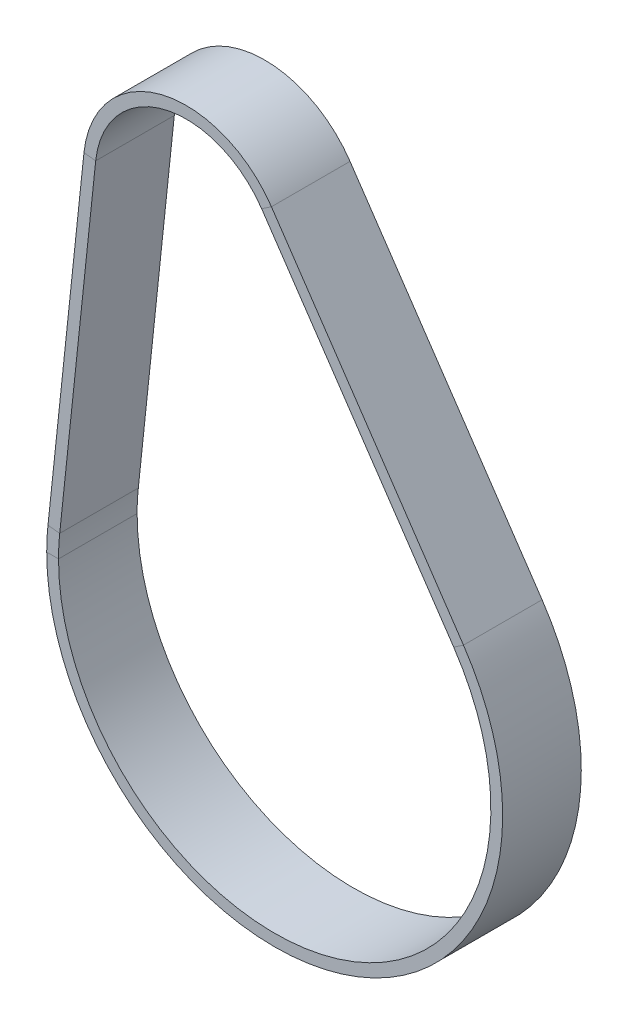
from build123d import *

# Parameters (mm, degrees)
SKETCH_3_W = 3
SKETCH_3_H = 20


with BuildPart() as part:
    # 扫描1: sweep along a path in 草图2
    with BuildLine(Plane.XY) as sweep_1_path:
        Line((-56.997873172, 6.020936707), (-47.843990191, 92.677197452))
        ThreePointArc((-47.843990191, 92.677197452), (-28.681020404, 114.724081616), (-1.397513338, 104.288816665))
        Line((-1.397513338, 104.288816665), (47.458859055, 32.135119764))
        ThreePointArc((47.458859055, 32.135119764), (13.900929349, -55.603717396), (-56.997873172, 6.020936707))
    # 草图3 → 扫描1 (sweep)
    with BuildSketch(Plane(origin=(0, 0, 0), x_dir=(1, 0, 0), z_dir=(0, 1, 0))):
        with Locations((-56.5, 0)):
            Rectangle(SKETCH_3_W, SKETCH_3_H)
    sweep(path=sweep_1_path.line)


solid = part.part
